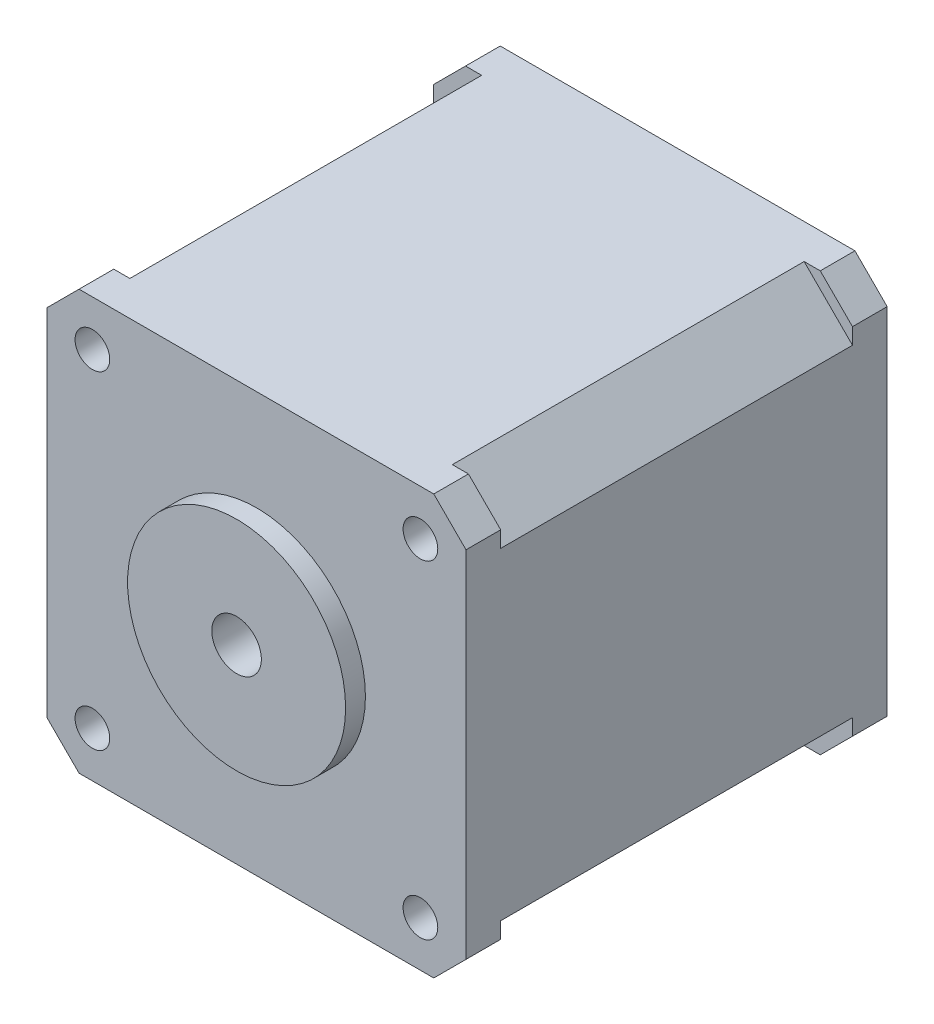
from build123d import *

# Parameters (mm, degrees)
SKETCH1_W                = 42.3
SKETCH1_H                = 42.3
BOSS_EXTRUDE1_DEPTH      = 42.5
SKETCH2_R                = 11
BOSS_EXTRUDE2_DEPTH      = 2
SKETCH3_R                = 1.75
CUT_EXTRUDE1_DEPTH       = 43.5
CUT_EXTRUDE2_DEPTH       = 43.5
SKETCH5_R                = 2.5
CUT_EXTRUDE3_DEPTH       = 45.5
SKETCH6_R                = 2.5
BOSS_EXTRUDE3_DEPTH      = 22
BOSS_EXTRUDE3_DEPTH_BACK = 47.5
SKETCH7_R                = 5
SKETCH7_R_2              = 2.5
CUT_EXTRUDE4_DEPTH       = 5
CUT_EXTRUDE5_DEPTH       = 20
SKETCH9_R                = 2.5
CUT_EXTRUDE6_DEPTH       = 70.5
CUT_EXTRUDE7_DEPTH       = 35.5


with BuildPart() as part:
    # Sketch1 → Boss-Extrude1 (new body)
    with BuildSketch(Plane.XY):
        Rectangle(SKETCH1_W, SKETCH1_H)
    extrude(amount=BOSS_EXTRUDE1_DEPTH)

    # Sketch2 → Boss-Extrude2 (add)
    with BuildSketch(Plane.XY.offset(42.5)):
        Circle(SKETCH2_R)
    extrude(amount=BOSS_EXTRUDE2_DEPTH)

    # Sketch3 → Cut-Extrude1 (cut, through all)
    with BuildSketch(Plane.XY.offset(42.5)):
        with Locations((-16.55, 16.55)):
            Circle(SKETCH3_R)
        with Locations((16.55, 16.55)):
            Circle(SKETCH3_R)
        with Locations((16.55, -16.55)):
            Circle(SKETCH3_R)
        with Locations((-16.55, -16.55)):
            Circle(SKETCH3_R)
    extrude(amount=-CUT_EXTRUDE1_DEPTH, mode=Mode.SUBTRACT)

    # Sketch4 → Cut-Extrude2 (cut, through all)
    with BuildSketch(Plane.XY.offset(42.5)):
        Polygon((-21.15, 17.897308807), (-21.15, 21.15), (-17.897308807, 21.15), align=None)
        Polygon((17.897308807, 21.15), (21.15, 21.15), (21.15, 17.897308807), align=None)
        Polygon((21.15, -17.897308807), (21.15, -21.15), (17.897308807, -21.15), align=None)
        Polygon((-17.897308807, -21.15), (-21.15, -21.15), (-21.15, -17.897308807), align=None)
    extrude(amount=-CUT_EXTRUDE2_DEPTH, mode=Mode.SUBTRACT)

    # Sketch5 → Cut-Extrude3 (cut, through all)
    with BuildSketch(Plane.XY.offset(44.5)):
        Circle(SKETCH5_R)
    extrude(amount=-CUT_EXTRUDE3_DEPTH, mode=Mode.SUBTRACT)

    # Sketch6 → Boss-Extrude3 (add, two sides)
    with BuildSketch(Plane.XY.offset(44.5)) as boss_extrude3_sk:
        Circle(SKETCH6_R)
    extrude(amount=BOSS_EXTRUDE3_DEPTH)
    extrude(boss_extrude3_sk.sketch, amount=-BOSS_EXTRUDE3_DEPTH_BACK)

    # Sketch7 → Cut-Extrude4 (cut)
    with BuildSketch(Plane(origin=(0, 0, 0), x_dir=(-1, 0, 0), z_dir=(0, 0, -1))):
        Circle(SKETCH7_R)
        Circle(SKETCH7_R_2, mode=Mode.SUBTRACT)
    extrude(amount=-CUT_EXTRUDE4_DEPTH, mode=Mode.SUBTRACT)

    # Sketch8 → Cut-Extrude5 (cut)
    with BuildSketch(Plane.XY.offset(66.5)):
        with BuildLine():
            Line((2.5, 0), (0, 2.5))
            ThreePointArc((0, 2.5), (1.767766953, 1.767766953), (2.5, 0))
        make_face()
    extrude(amount=-CUT_EXTRUDE5_DEPTH, mode=Mode.SUBTRACT)

    # Sketch9 → Cut-Extrude6 (cut, through all)
    with BuildSketch(Plane.XY.offset(66.5)):
        Circle(SKETCH9_R)
    extrude(amount=-CUT_EXTRUDE6_DEPTH, mode=Mode.SUBTRACT)

    # Sketch10 → Cut-Extrude7 (cut)
    with BuildSketch(Plane.XY.offset(3.5)):
        Polygon((25, -25), (12.42096321, -25), (25, -12.42096321), align=None)
        Polygon((25, 25), (12.42096321, 25), (25, 12.42096321), align=None)
        Polygon((-25, -25), (-25, -12.42096321), (-12.42096321, -25), align=None)
        Polygon((-25, 12.42096321), (-25, 25), (-12.42096321, 25), align=None)
    extrude(amount=CUT_EXTRUDE7_DEPTH, mode=Mode.SUBTRACT)


solid = part.part
